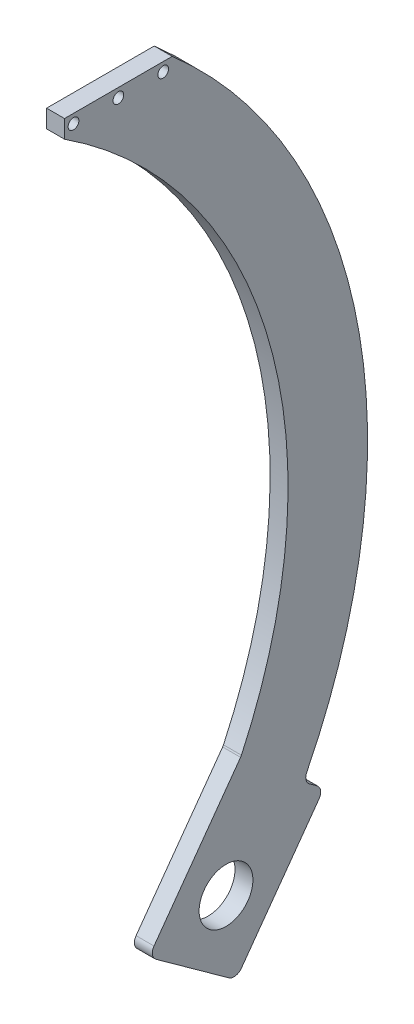
from build123d import *

# Parameters (mm, degrees)
SKETCH1_R                 = 9.525
BOSS_EXTRUDE1_DEPTH       = 6.35
FILLET1_R                 = 3.175
F_6_CLEARANCE_HOLE1_D     = 3.7973
F_6_CLEARANCE_HOLE1_DEPTH = 6.35


with BuildPart() as part:
    # Sketch1 → Boss-Extrude1 (new body)
    with BuildSketch(Plane(origin=(0, 0, 0), x_dir=(0, 0, -1), z_dir=(1, 0, 0))):
        with BuildLine():
            Line((-19.05, 266.7), (19.05, 266.7))
            ThreePointArc((19.05, 266.7), (84.689584794, 151.864978949), (65.432294388, 21.003243067))
            Line((65.432294388, 21.003243067), (72.860995986, 15.649155186))
            Line((72.860995986, 15.649155186), (41.67338239, -27.623103343))
            Line((41.67338239, -27.623103343), (10.764626298, -5.346236488))
            Line((10.764626298, -5.346236488), (41.952239895, 37.92602204))
            Line((41.952239895, 37.92602204), (43.433779152, 39.981631379))
            ThreePointArc((43.433779152, 39.981631379), (53.452056919, 161.864823129), (-19.05, 260.35))
            Line((-19.05, 260.35), (-19.05, 266.7))
        make_face()
        with Locations((38.1, 0)):
            Circle(SKETCH1_R, mode=Mode.SUBTRACT)
    extrude(amount=BOSS_EXTRUDE1_DEPTH)

    # Fillet1
    fillet1_edges = [part.edges().sort_by_distance(p)[0] for p in [
        (3.175, 21.003243067, -65.432294388),
        (3.175, 15.649155186, -72.860995986),
        (3.175, -27.623103343, -41.67338239),
        (3.175, -5.346236488, -10.764626298),
        (3.175, 39.981631379, -43.433779152),
    ]]
    fillet(fillet1_edges, radius=FILLET1_R)

    # #6 Clearance Hole1
    with Locations(Plane(origin=(6.35, 0, 0), x_dir=(0, 0, -1), z_dir=(1, 0, 0))):
        with Locations((-15.875, 263.525), (15.875, 263.525), (0, 263.525)):
            Hole(F_6_CLEARANCE_HOLE1_D / 2, depth=F_6_CLEARANCE_HOLE1_DEPTH)


solid = part.part
